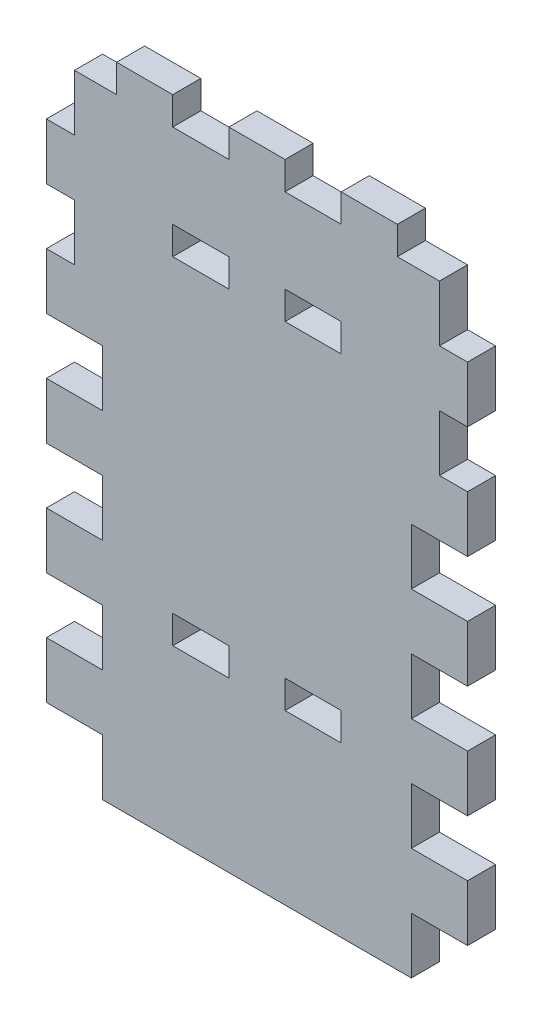
from build123d import *

# Parameters (mm, degrees)
SKETCH1_W           = 95.25
SKETCH1_H           = 177.8
BOSS_EXTRUDE1_DEPTH = 6.35
SKETCH2_W           = 12.7
SKETCH2_H           = 12.7
CUT_EXTRUDE1_DEPTH  = 7.35
LPATTERN1_COUNT     = 4
LPATTERN1_PITCH     = 25.4
SKETCH3_W           = 12.7
SKETCH3_H           = 6.35
CUT_EXTRUDE2_DEPTH  = 7.35
SKETCH5_W           = 6.35
SKETCH5_H           = 12.7
CUT_EXTRUDE4_DEPTH  = 7.35
LPATTERN2_COUNT     = 4
LPATTERN2_PITCH     = 25.4
SKETCH6_W           = 95.25
SKETCH6_H           = 38.1
CUT_EXTRUDE5_DEPTH  = 7.35
SKETCH7_W           = 12.7
SKETCH7_H           = 6.35
BOSS_EXTRUDE2_DEPTH = 6.35
LPATTERN3_COUNT     = 2
LPATTERN3_PITCH     = 25.4
LPATTERN3_COL_COUNT = 2
LPATTERN3_COL_PITCH = 25.4
LPATTERN4_COUNT     = 2
LPATTERN4_PITCH     = 76.2


with BuildPart() as part:
    # Sketch1 → Boss-Extrude1 (new body)
    with BuildSketch(Plane.XY):
        with Locations((47.625, 88.9)):
            Rectangle(SKETCH1_W, SKETCH1_H)
    extrude(amount=BOSS_EXTRUDE1_DEPTH)

    # Sketch2 → Cut-Extrude1 (cut, through all)
    with BuildSketch(Plane.XY.offset(6.35)):
        with Locations((6.35, 6.35)):
            Rectangle(SKETCH2_W, SKETCH2_H)
        with Locations((88.9, 6.35)):
            Rectangle(SKETCH2_W, SKETCH2_H)
    cut_extrude1 = extrude(amount=-CUT_EXTRUDE1_DEPTH, mode=Mode.SUBTRACT)

    # LPattern1: Cut-Extrude1 ×4
    with Locations(*[(0, i * LPATTERN1_PITCH, 0) for i in range(1, LPATTERN1_COUNT)]):
        add(cut_extrude1, mode=Mode.SUBTRACT)

    # Sketch3 → Cut-Extrude2 (cut, through all)
    with BuildSketch(Plane.XY.offset(6.35)):
        with Locations((34.925, 41.275)):
            Rectangle(SKETCH3_W, SKETCH3_H)
        with Locations((60.325, 41.275)):
            Rectangle(SKETCH3_W, SKETCH3_H)
    cut_extrude2 = extrude(amount=-CUT_EXTRUDE2_DEPTH, mode=Mode.SUBTRACT)

    # Sketch5 → Cut-Extrude4 (cut, through all)
    with BuildSketch(Plane.XY.offset(6.35)):
        with Locations((3.175, 107.95)):
            Rectangle(SKETCH5_W, SKETCH5_H)
        with Locations((92.075, 107.95)):
            Rectangle(SKETCH5_W, SKETCH5_H)
    cut_extrude4 = extrude(amount=-CUT_EXTRUDE4_DEPTH, mode=Mode.SUBTRACT)

    # LPattern2: Cut-Extrude4 ×4
    with Locations(*[(0, i * LPATTERN2_PITCH, 0) for i in range(1, LPATTERN2_COUNT)]):
        add(cut_extrude4, mode=Mode.SUBTRACT)

    # Sketch6 → Cut-Extrude5 (cut, through all)
    with BuildSketch(Plane.XY.offset(6.35)):
        with Locations((47.625, 158.75)):
            Rectangle(SKETCH6_W, SKETCH6_H)
    extrude(amount=-CUT_EXTRUDE5_DEPTH, mode=Mode.SUBTRACT)

    # Sketch7 → Boss-Extrude2 (add)
    with BuildSketch(Plane(origin=(0, 139.7, 0), x_dir=(1, 0, 0), z_dir=(0, 1, 0))):
        with Locations((47.625, -3.175)):
            Rectangle(SKETCH7_W, SKETCH7_H)
    boss_extrude2 = extrude(amount=BOSS_EXTRUDE2_DEPTH)

    # LPattern3: Boss-Extrude2 ×2
    with Locations(*[(i * LPATTERN3_PITCH, 0, 0) for i in range(1, LPATTERN3_COUNT)]):
        add(boss_extrude2)

    # LPattern3 col: Boss-Extrude2 ×2
    with Locations(*[(-i * LPATTERN3_COL_PITCH, 0, 0) for i in range(1, LPATTERN3_COL_COUNT)]):
        add(boss_extrude2)

    # LPattern4: Cut-Extrude2 ×2
    with Locations(*[(0, i * LPATTERN4_PITCH, 0) for i in range(1, LPATTERN4_COUNT)]):
        add(cut_extrude2, mode=Mode.SUBTRACT)


solid = part.part
